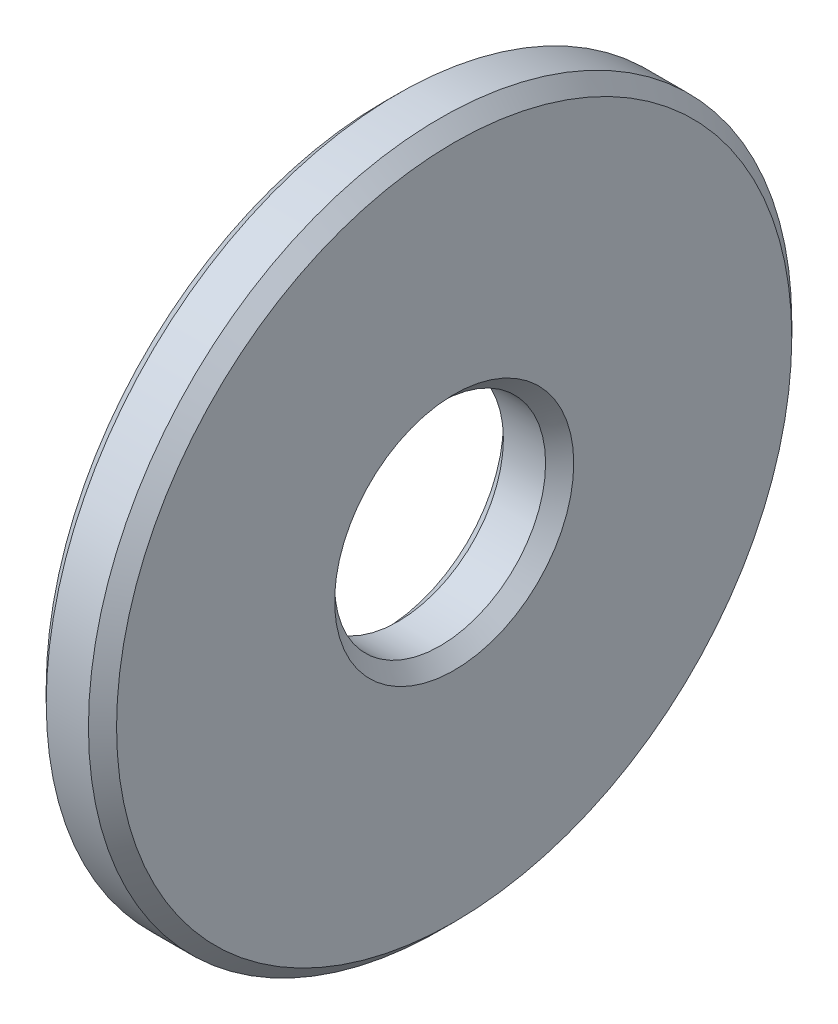
from build123d import *


with BuildPart() as part:
    # Sketch1 → Revolve1 (revolve)
    with BuildSketch(Plane.XY):
        Polygon((0, 4.8), (0, 1.7), (0.2, 1.5), (0.8, 1.5), (1, 1.7), (1, 4.8), (0.8, 5), (0.2, 5), align=None)
    revolve(axis=Axis((0, 0, 0), (1, 0, 0)))


solid = part.part
